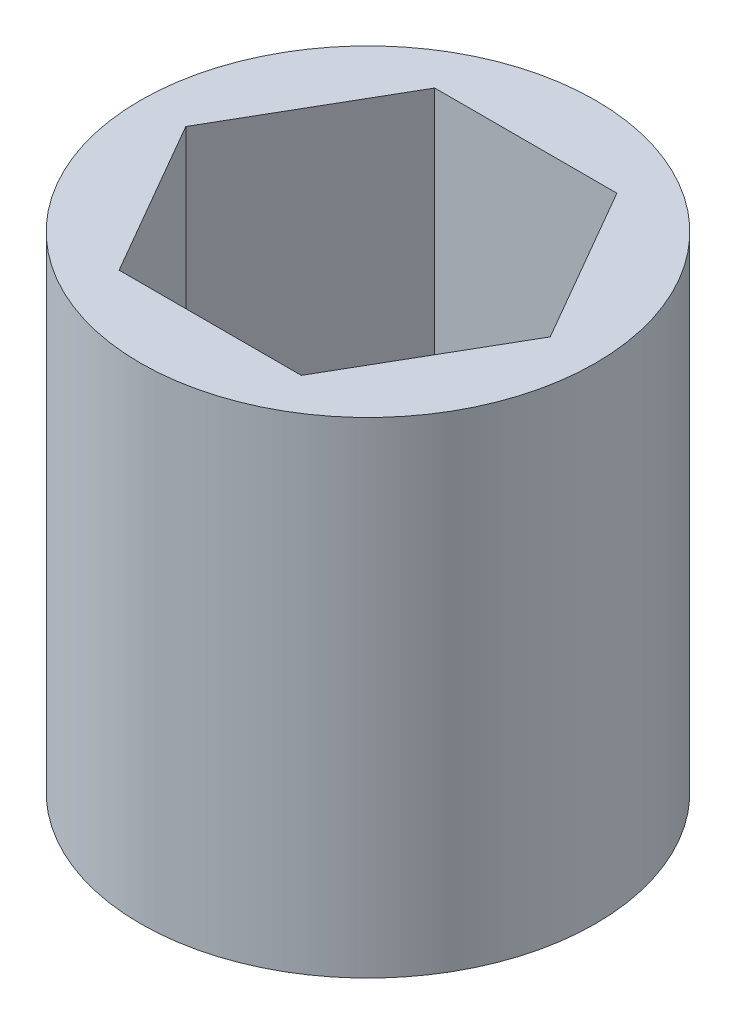
from build123d import *

# Parameters (mm, degrees)
SKETCH1_R           = 9.525
BOSS_EXTRUDE1_DEPTH = 20.32


with BuildPart() as part:
    # Sketch1 → Boss-Extrude1 (new body)
    with BuildSketch(Plane(origin=(0, 0, 0), x_dir=(1, 0, 0), z_dir=(0, 1, 0))):
        Circle(SKETCH1_R)
        Polygon((3.812821178, 6.604), (-3.812821178, 6.604), (-7.625642355, 0), (-3.812821178, -6.604), (3.812821178, -6.604), (7.625642355, 0), align=None, mode=Mode.SUBTRACT)
    extrude(amount=BOSS_EXTRUDE1_DEPTH)


solid = part.part
